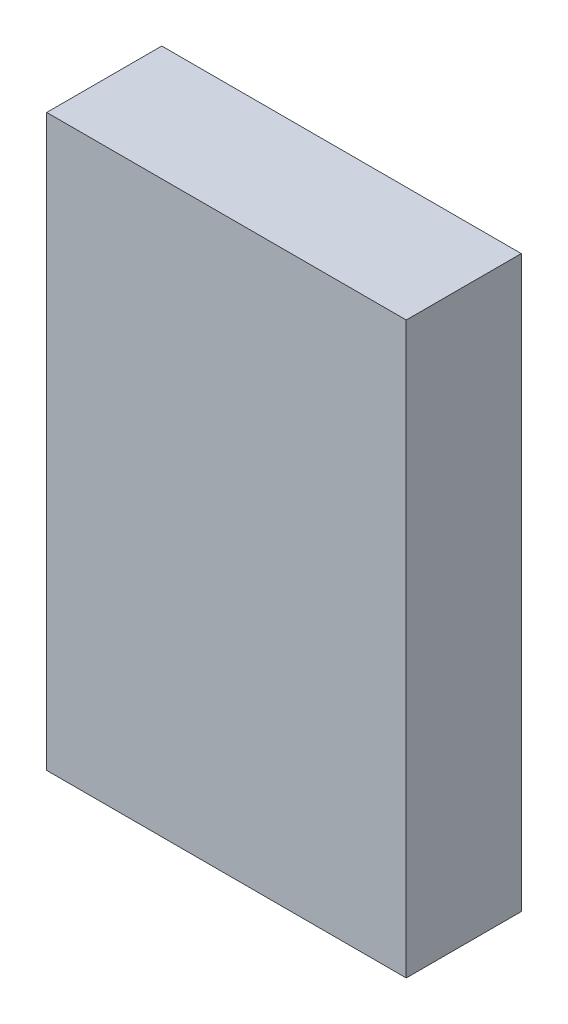
from build123d import *

# Parameters (mm, degrees)
SKETCH1_W           = 5
SKETCH1_H           = 7.925
BOSS_EXTRUDE1_DEPTH = 1.6


with BuildPart() as part:
    # Sketch1 → Boss-Extrude1 (new body)
    with BuildSketch(Plane.XY):
        with Locations((2.5, 65.388089021)):
            Rectangle(SKETCH1_W, SKETCH1_H)
    extrude(amount=BOSS_EXTRUDE1_DEPTH)


solid = part.part
